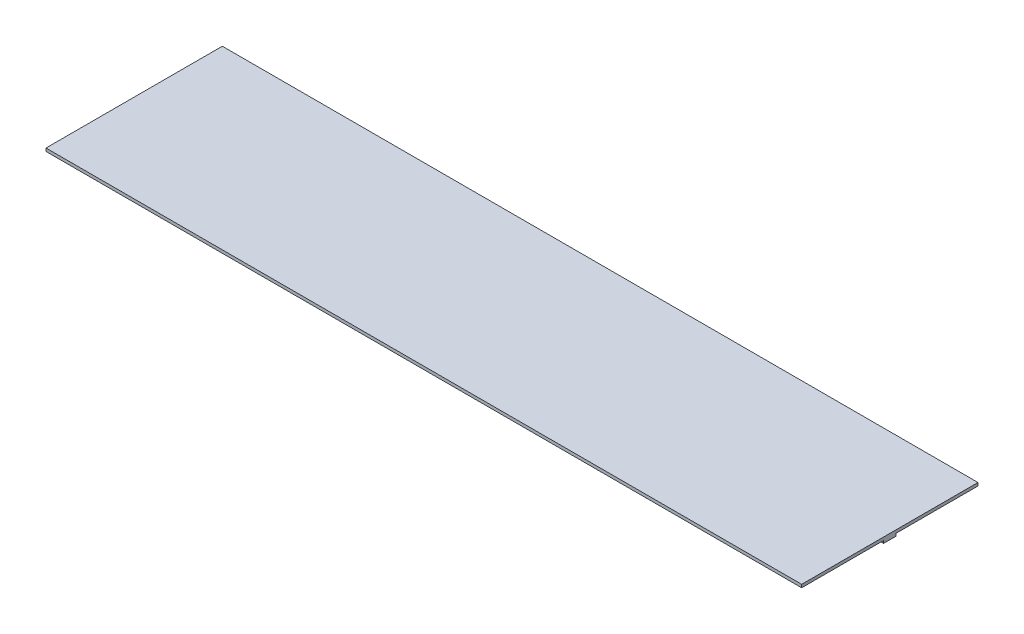
from build123d import *

# Parameters (mm, degrees)
SKETCH1_W           = 30
SKETCH1_H           = 7
BOSS_EXTRUDE1_DEPTH = 0.12
SKETCH2_W           = 0.5
SKETCH2_H           = 0.5
BOSS_EXTRUDE2_DEPTH = 0.1
SKETCH3_W           = 0.5
SKETCH3_H           = 0.5
BOSS_EXTRUDE3_DEPTH = 0.1


with BuildPart() as part:
    # Sketch1 → Boss-Extrude1 (new body)
    with BuildSketch(Plane(origin=(0, 0, 0), x_dir=(1, 0, 0), z_dir=(0, 1, 0))):
        with Locations((-15, -3.5)):
            Rectangle(SKETCH1_W, SKETCH1_H)
    extrude(amount=BOSS_EXTRUDE1_DEPTH)

    # Sketch2 → Boss-Extrude2 (add)
    with BuildSketch(Plane.XZ):
        with Locations((-0.25, 3.5)):
            Rectangle(SKETCH2_W, SKETCH2_H)
    extrude(amount=BOSS_EXTRUDE2_DEPTH)

    # Sketch3 → Boss-Extrude3 (add)
    with BuildSketch(Plane.XZ):
        with Locations((-29.75, 3.5)):
            Rectangle(SKETCH3_W, SKETCH3_H)
    extrude(amount=BOSS_EXTRUDE3_DEPTH)


solid = part.part
